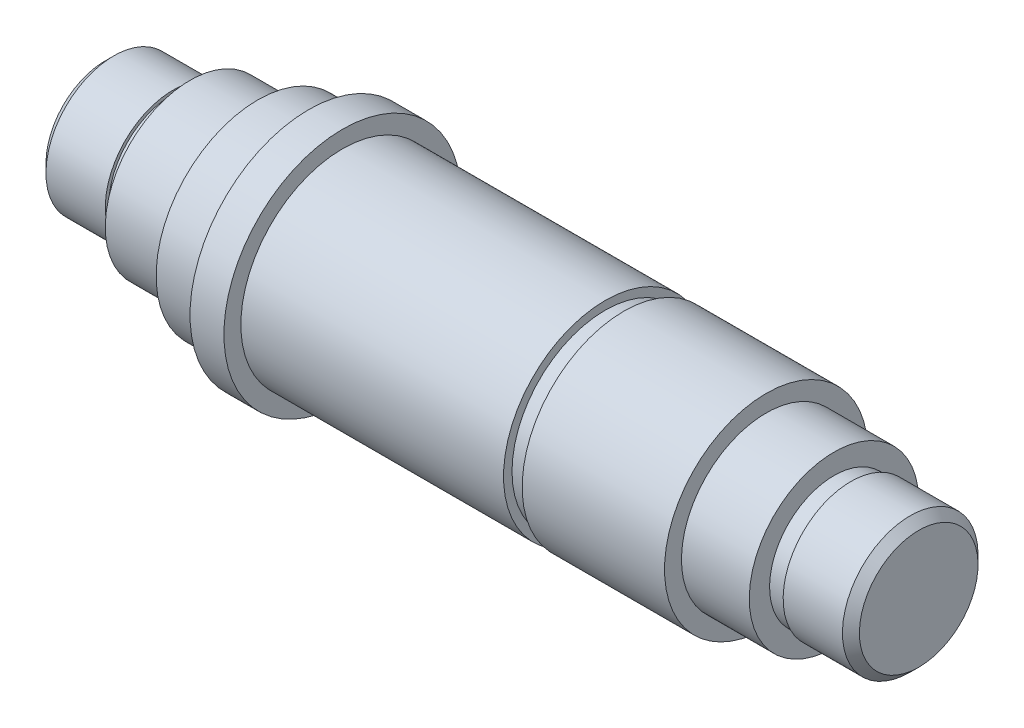
from build123d import *


with BuildPart() as part:
    # 草图1 → 旋转1 (revolve)
    with BuildSketch(Plane.XY):
        Polygon((-10.764397906, 0), (37.235602094, 0), (37.235602094, 3.5), (36.735602094, 4), (33.235602094, 4), (33.235602094, 3.8), (32.235602094, 3.8), (32.235602094, 3.95), (32.235602094, 5), (28.235602094, 5), (28.235602094, 6), (19.835602094, 6), (19.835602094, 5.5), (18.735602094, 5.5), (18.735602094, 6), (3.235602094, 6), (3.235602094, 7), (1.235602094, 7), (1.235602094, 6), (-1.764397906, 6), (-1.764397906, 5), (-5.764397906, 5), (-5.764397906, 3.95), (-5.764397906, 3.8), (-6.764397906, 3.8), (-6.764397906, 4), (-10.264397906, 4), (-10.764397906, 3.5), align=None)
    revolve(axis=Axis((-10.764397906, 0, 0), (1, 0, 0)))


solid = part.part
